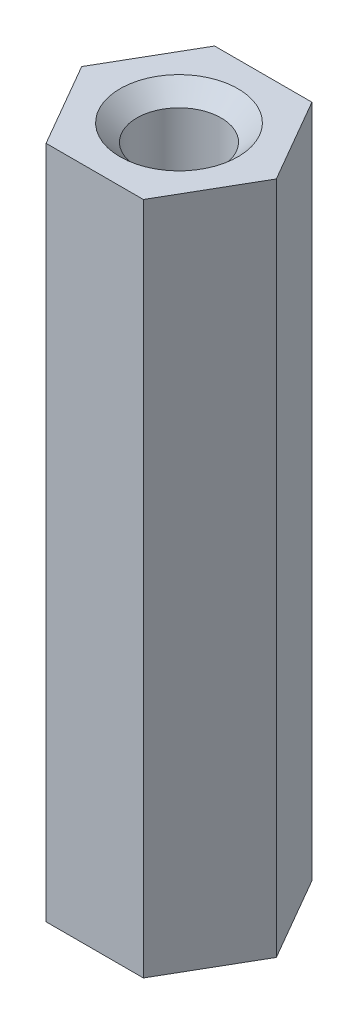
from build123d import *

# Parameters (mm, degrees)
EXTRUDE_1_DEPTH = 20


with BuildPart() as part:
    # Эскиз1 → Бобышка-Вытянуть1 (new body)
    with BuildSketch(Plane(origin=(0, 0, 0), x_dir=(1, 0, 0), z_dir=(0, 1, 0))):
        Polygon((2.886751346, 0), (1.443375673, 2.5), (-1.443375673, 2.5), (-2.886751346, 0), (-1.443375673, -2.5), (1.443375673, -2.5), align=None)
    extrude(amount=EXTRUDE_1_DEPTH)

    # Эскиз2 → Отверстие обработанное метчиком M3x0.51 (revolve, cut)
    with BuildSketch(Plane(origin=(0, 20, 0), x_dir=(0, 0, 1), z_dir=(1, 0, 0))):
        Polygon((0, 0), (0, 20), (1.75, 20), (1.25, 19.5), (1.25, 0.5), (1.75, 0), align=None)
    revolve(axis=Axis((0, 26.35, 0), (0, -1, 0)), mode=Mode.SUBTRACT)


solid = part.part
